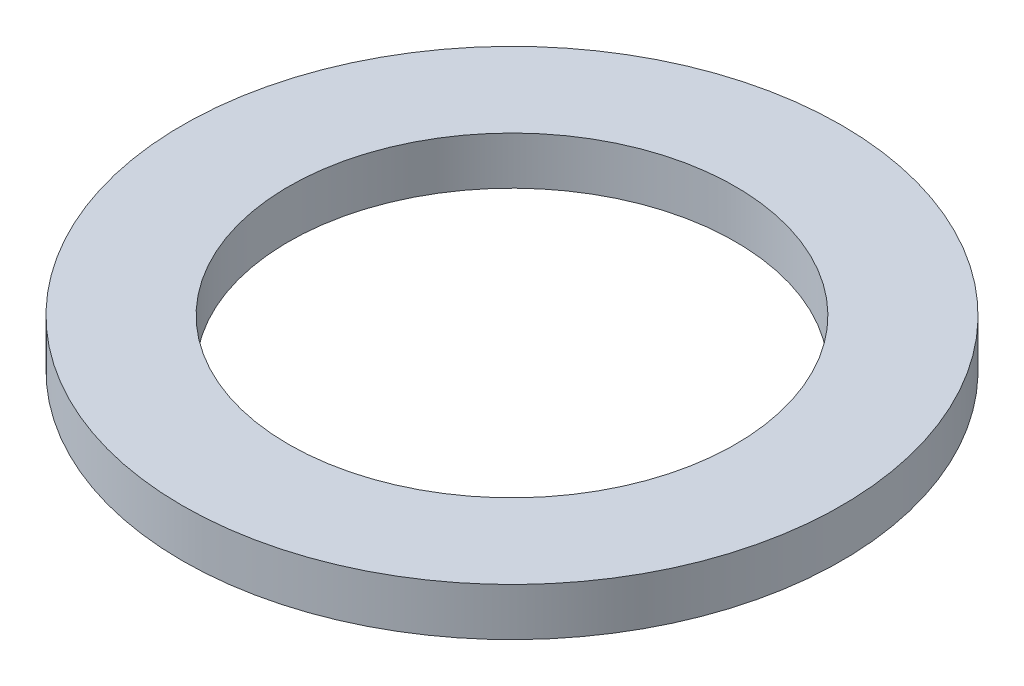
from build123d import *

# Parameters (mm, degrees)
SKETCH1_R           = 9.4615
BOSS_EXTRUDE1_DEPTH = 1.3716
SKETCH5_R           = 6.4135
CUT_EXTRUDE1_DEPTH  = 2.3716


with BuildPart() as part:
    # Sketch1 → Boss-Extrude1 (new body)
    with BuildSketch(Plane(origin=(0, 0, 0), x_dir=(1, 0, 0), z_dir=(0, 1, 0))):
        Circle(SKETCH1_R)
    extrude(amount=BOSS_EXTRUDE1_DEPTH)

    # Sketch5 → Cut-Extrude1 (cut, through all)
    with BuildSketch(Plane(origin=(0, 1.3716, 0), x_dir=(-1, 0, 0), z_dir=(0, 1, 0))):
        Circle(SKETCH5_R)
    extrude(amount=-CUT_EXTRUDE1_DEPTH, mode=Mode.SUBTRACT)


solid = part.part
